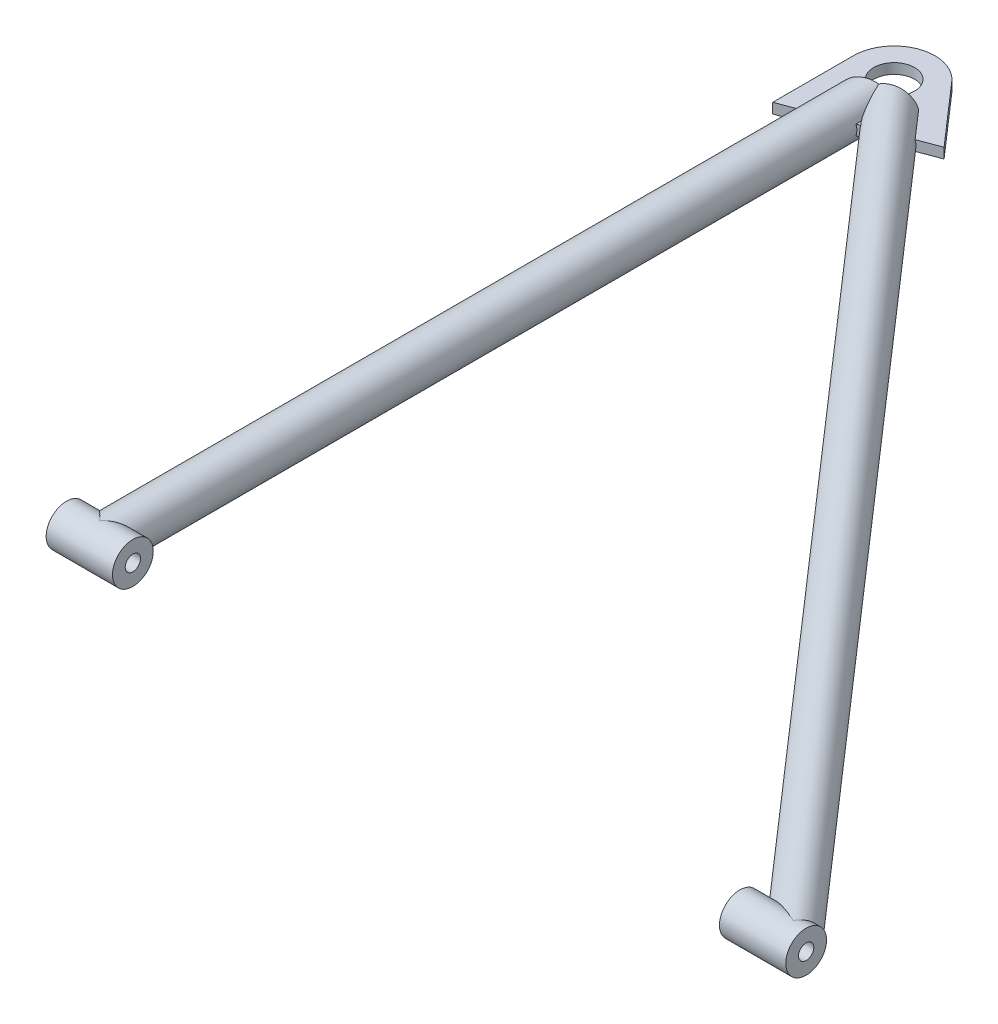
from build123d import *

# Parameters (mm, degrees)
SKETCH11_ON_SEGMENT_1_R         = 12.7
SKETCH11_ON_SEGMENT_1_R_2       = 11.049
STRUCTURAL_MEMBER1_DEPTH        = 543.415718856
SKETCH11_R                      = 12.7
SKETCH11_R_2                    = 11.049
STRUCTURAL_MEMBER1_2_DEPTH      = 656.520428809
STRUCTURAL_MEMBER1_2_DEPTH_BACK = 48.877718856
CUT_EXTRUDE1_DEPTH              = 670.227159455
CUT_EXTRUDE1_DEPTH_BACK         = 670.227159455
BOSS_EXTRUDE1_DEPTH             = 3.175
BOSS_EXTRUDE1_DEPTH_BACK        = 3.175
SKETCH16_R                      = 12.7
CUT_EXTRUDE2_DEPTH              = 683.129929993
CUT_EXTRUDE2_DEPTH_BACK         = 683.129929993
SKETCH17_R                      = 12.7
BOSS_EXTRUDE2_DEPTH             = 20.6375
BOSS_EXTRUDE2_DEPTH_BACK        = 20.6375
SKETCH18_R                      = 12.7
BOSS_EXTRUDE3_DEPTH             = 7.9375
BOSS_EXTRUDE3_DEPTH_BACK        = 33.3375
SKETCH19_W                      = 4.7625
SKETCH19_H                      = 460.375
SKETCH22_R                      = 12.7
CUT_EXTRUDE3_DEPTH              = 682.143603345
CUT_EXTRUDE3_DEPTH_BACK         = 682.143603345


with BuildPart() as part:
    # Sketch11 on segment 1 (carried to segment 1) → Structural Member1 (new body)
    with BuildSketch(Plane(origin=(0, 0, 0), x_dir=(-1, 0, 0), z_dir=(0, 0, -1))):
        Circle(SKETCH11_ON_SEGMENT_1_R)
        Circle(SKETCH11_ON_SEGMENT_1_R_2, mode=Mode.SUBTRACT)
    extrude(amount=STRUCTURAL_MEMBER1_DEPTH)

    # Structural Member1 mitre 1
    split(bisect_by=Plane(origin=(0, 0, -494.538), x_dir=(0, -1, 0), z_dir=(-0.936288231, 0, 0.351232612)), keep=Keep.TOP)


with BuildPart() as body_2:
    # Sketch11 → Structural Member1 2 (new, two sides)
    with BuildSketch(Plane(origin=(0, 0, -494.538), x_dir=(0.7532713047435399, 0, -0.6577099219640564), z_dir=(0.6577099219640563, 0, 0.7532713047435398))) as structural_member1_2_sk:
        Circle(SKETCH11_R)
        Circle(SKETCH11_R_2, mode=Mode.SUBTRACT)
    extrude(amount=STRUCTURAL_MEMBER1_2_DEPTH)
    extrude(structural_member1_2_sk.sketch, amount=-STRUCTURAL_MEMBER1_2_DEPTH_BACK)

    # Structural Member1 2 mitre 1
    split(bisect_by=Plane(origin=(0, 0, -494.538), x_dir=(0, 1, 0), z_dir=(0.936288231, 0, -0.351232612)), keep=Keep.TOP)


with BuildPart() as part_1:
    add(part.part)

    # Structural Member1 as one body: union body 2
    add(body_2.part)

    # Sketch13 → Cut-Extrude1 (cut, two sides)
    with BuildSketch(Plane(origin=(0, 0, -494.538), x_dir=(0.35123261185178917, 0, 0.9362882314606814), z_dir=(-0.9362882314606813, 0, 0.3512326118517891))) as cut_extrude1_sk:
        Polygon((16.51, 3.175), (38.1, 3.175), (38.1, -3.175), (16.51, -3.175), (16.51, -12.7), (-36.1583736, -12.7), (-36.1583736, 12.7), (16.51, 12.7), align=None)
    extrude(amount=CUT_EXTRUDE1_DEPTH, mode=Mode.SUBTRACT)
    extrude(cut_extrude1_sk.sketch, amount=-CUT_EXTRUDE1_DEPTH_BACK, mode=Mode.SUBTRACT)

    # Sketch16 → Cut-Extrude2 (cut, two sides)
    with BuildSketch(Plane(origin=(0, 0, 0), x_dir=(0, 0, -1), z_dir=(1, 0, 0))) as cut_extrude2_sk:
        Circle(SKETCH16_R)
    extrude(amount=CUT_EXTRUDE2_DEPTH, mode=Mode.SUBTRACT)
    extrude(cut_extrude2_sk.sketch, amount=-CUT_EXTRUDE2_DEPTH_BACK, mode=Mode.SUBTRACT)


with BuildPart() as body_2_2:
    # Sketch12 → Boss-Extrude1 (new, two sides)
    with BuildSketch(Plane(origin=(0, 0, 0), x_dir=(1, 0, 0), z_dir=(0, 1, 0))) as boss_extrude1_sk:
        with BuildLine():
            Line((19.13309114, 511.243832018), (52.163925023, 473.413812271))
            Line((52.163925023, 473.413812271), (-25.4, 444.317024492))
            Line((-25.4, 444.317024492), (-25.4, 494.538))
            ThreePointArc((-25.4, 494.538), (-8.921308341, 518.319721079), (19.13309114, 511.243832018))
        make_face()
    extrude(amount=BOSS_EXTRUDE1_DEPTH)
    extrude(boss_extrude1_sk.sketch, amount=-BOSS_EXTRUDE1_DEPTH_BACK)

    # Sketch22 → Cut-Extrude3 (cut, two sides)
    with BuildSketch(Plane(origin=(0, 3.175, 0), x_dir=(1, 0, 0), z_dir=(0, 1, 0))) as cut_extrude3_sk:
        with Locations(Location((0, 494.538, 0), (0, 0, 270))):
            Circle(SKETCH22_R)
    extrude(amount=CUT_EXTRUDE3_DEPTH, mode=Mode.SUBTRACT)
    extrude(cut_extrude3_sk.sketch, amount=-CUT_EXTRUDE3_DEPTH_BACK, mode=Mode.SUBTRACT)


with BuildPart() as body_3:
    # Sketch17 → Boss-Extrude2 (new, two sides)
    with BuildSketch(Plane(origin=(0, 0, 0), x_dir=(0, 0, -1), z_dir=(1, 0, 0))) as boss_extrude2_sk:
        Circle(SKETCH17_R)
    extrude(amount=BOSS_EXTRUDE2_DEPTH)
    extrude(boss_extrude2_sk.sketch, amount=-BOSS_EXTRUDE2_DEPTH_BACK)


with BuildPart() as body_4:
    # Sketch18 → Boss-Extrude3 (new, two sides)
    with BuildSketch(Plane(origin=(431.8, 0, 0), x_dir=(0, 0, -1), z_dir=(1, 0, 0))) as boss_extrude3_sk:
        Circle(SKETCH18_R)
    extrude(amount=BOSS_EXTRUDE3_DEPTH)
    extrude(boss_extrude3_sk.sketch, amount=-BOSS_EXTRUDE3_DEPTH_BACK)


with BuildPart() as f_1_2_0_5_diameter_hole2_tool:
    # Sketch19 → 1_2 _0.5_ Diameter Hole2 (revolve)
    with BuildSketch(Plane(origin=(-20.6375, 0, 0), x_dir=(0, 0, 1), z_dir=(0, 1, 0))):
        with Locations((2.38125, 230.1875)):
            Rectangle(SKETCH19_W, SKETCH19_H)
    revolve(axis=Axis((-26.9875, 0, 0), (1, 0, 0)))


with BuildPart() as body_3_1:
    add(body_3.part)

    # 1_2 _0.5_ Diameter Hole2: cut by f_1_2_0_5_diameter_hole2_tool
    add(f_1_2_0_5_diameter_hole2_tool.part, mode=Mode.SUBTRACT)


with BuildPart() as body_4_1:
    add(body_4.part)

    # 1_2 _0.5_ Diameter Hole2: cut by f_1_2_0_5_diameter_hole2_tool
    add(f_1_2_0_5_diameter_hole2_tool.part, mode=Mode.SUBTRACT)


solid = Compound([part_1.part, body_2_2.part, body_3_1.part, body_4_1.part])
